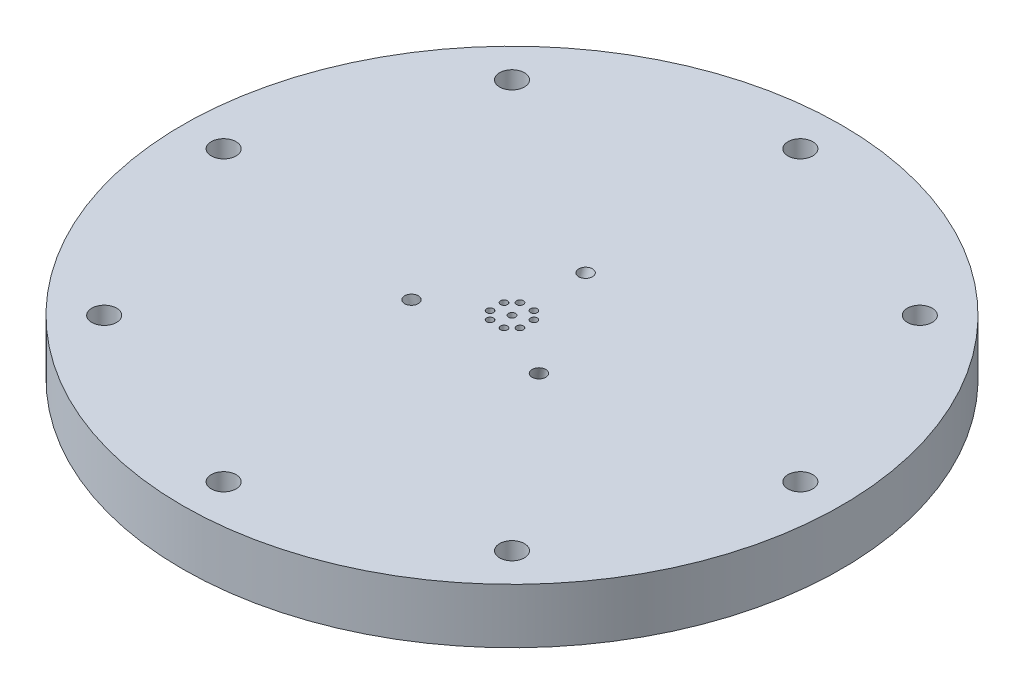
from build123d import *

# Parameters (mm, degrees)
SKETCH1_R                                      = 38.1
BOSS_EXTRUDE1_DEPTH                            = 6.35
CBORE_FOR_4_BUTTON_HEAD_CAP_SCREW1_D           = 2.8702
CBORE_FOR_4_BUTTON_HEAD_CAP_SCREW1_CBORE_D     = 4.826
CBORE_FOR_4_BUTTON_HEAD_CAP_SCREW1_CBORE_DEPTH = 3.175
CIRPATTERN1_COUNT                              = 8
SKETCH6_R                                      = 0.396875
CUT_EXTRUDE1_DEPTH                             = 55.254423783
CIRPATTERN2_COUNT                              = 4
SKETCH6_3_R                                    = 0.396875
CUT_EXTRUDE2_DEPTH                             = 55.254423783
SKETCH8_R                                      = 0.79375
CIRPATTERN4_COUNT                              = 3


with BuildPart() as part:
    # Sketch1 → Boss-Extrude1 (new body)
    with BuildSketch(Plane(origin=(0, 0, 0), x_dir=(1, 0, 0), z_dir=(0, 1, 0))):
        Circle(SKETCH1_R)
    extrude(amount=BOSS_EXTRUDE1_DEPTH)

    # CBORE for _4 Button Head Cap Screw1 (through all)
    with Locations(Plane(origin=(0, 0, 0), x_dir=(-1, 0, 0), z_dir=(0, -1, 0))):
        with Locations((0, -33.3375)):
            cbore_for_4_button_head_cap_screw1 = CounterBoreHole(CBORE_FOR_4_BUTTON_HEAD_CAP_SCREW1_D / 2, CBORE_FOR_4_BUTTON_HEAD_CAP_SCREW1_CBORE_D / 2, CBORE_FOR_4_BUTTON_HEAD_CAP_SCREW1_CBORE_DEPTH)

    # CirPattern1: CBORE for _4 Button Head Cap Screw1 ×8 about axis
    cirpattern1_axis = Axis((0, 0, 0), (0, 1, 0))
    for i in range(1, CIRPATTERN1_COUNT):
        add(cbore_for_4_button_head_cap_screw1.rotate(cirpattern1_axis, i * 360 / CIRPATTERN1_COUNT), mode=Mode.SUBTRACT)

    # Sketch6 → Cut-Extrude1 (cut, through all)
    with BuildSketch(Plane.XZ):
        with Locations((0.805087789, -1.726516334)):
            Circle(SKETCH6_R)
        with Locations((1.726516334, -0.805087789)):
            Circle(SKETCH6_R)
    cut_extrude1 = extrude(amount=-CUT_EXTRUDE1_DEPTH, mode=Mode.SUBTRACT)

    # CirPattern2: Cut-Extrude1 ×4 about axis
    cirpattern2_axis = Axis((0, 0, 0), (0, -1, 0))
    for i in range(1, CIRPATTERN2_COUNT):
        add(cut_extrude1.rotate(cirpattern2_axis, i * 360 / CIRPATTERN2_COUNT), mode=Mode.SUBTRACT)

    # Sketch6_3 → Cut-Extrude2 (cut, through all)
    with BuildSketch(Plane.XZ):
        Circle(SKETCH6_3_R)
    extrude(amount=-CUT_EXTRUDE2_DEPTH, mode=Mode.SUBTRACT)

    # Cut-Sweep2: sweep along a curve in space
    with BuildLine() as cut_sweep2_path:
        Line((0, 6.35, -8.509), (0, 0, -6.35))
    # Sketch8 → Cut-Sweep2 (sweep, cut)
    with BuildSketch(Plane(origin=(0, 6.35, 0), x_dir=(1, 0, 0), z_dir=(0, 1, 0))):
        with Locations((0, 8.509)):
            Circle(SKETCH8_R)
    cut_sweep2 = sweep(path=cut_sweep2_path.line, mode=Mode.SUBTRACT)

    # CirPattern4: Cut-Sweep2 ×3 about axis
    cirpattern4_axis = Axis((0, 6.35, 0), (0, -1, 0))
    for i in range(1, CIRPATTERN4_COUNT):
        add(cut_sweep2.rotate(cirpattern4_axis, i * 360 / CIRPATTERN4_COUNT), mode=Mode.SUBTRACT)


solid = part.part
